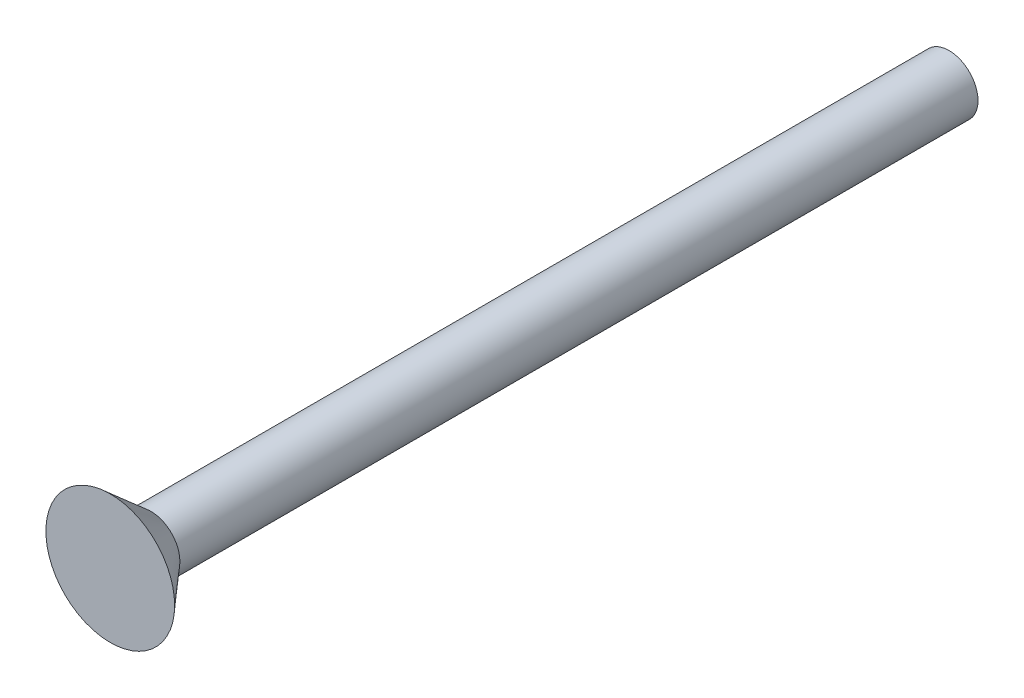
from build123d import *

# Parameters (mm, degrees)
SKETCH1_R           = 1.7526
BOSS_EXTRUDE1_DEPTH = 50.8


with BuildPart() as part:
    # Sketch1 → Boss-Extrude1 (new body)
    with BuildSketch(Plane.XY):
        Circle(SKETCH1_R)
    extrude(amount=-BOSS_EXTRUDE1_DEPTH)

    # Sketch3 → Revolve1 (revolve)
    with BuildSketch(Plane(origin=(0, 0, 0), x_dir=(0, 0, -1), z_dir=(1, 0, 0))):
        Polygon((0, 0), (2.4638, 0), (2.4638, 1.7526), (0, 3.8989), align=None)
    revolve(axis=Axis((0, 0, 0), (0, 0, -1)))


solid = part.part
